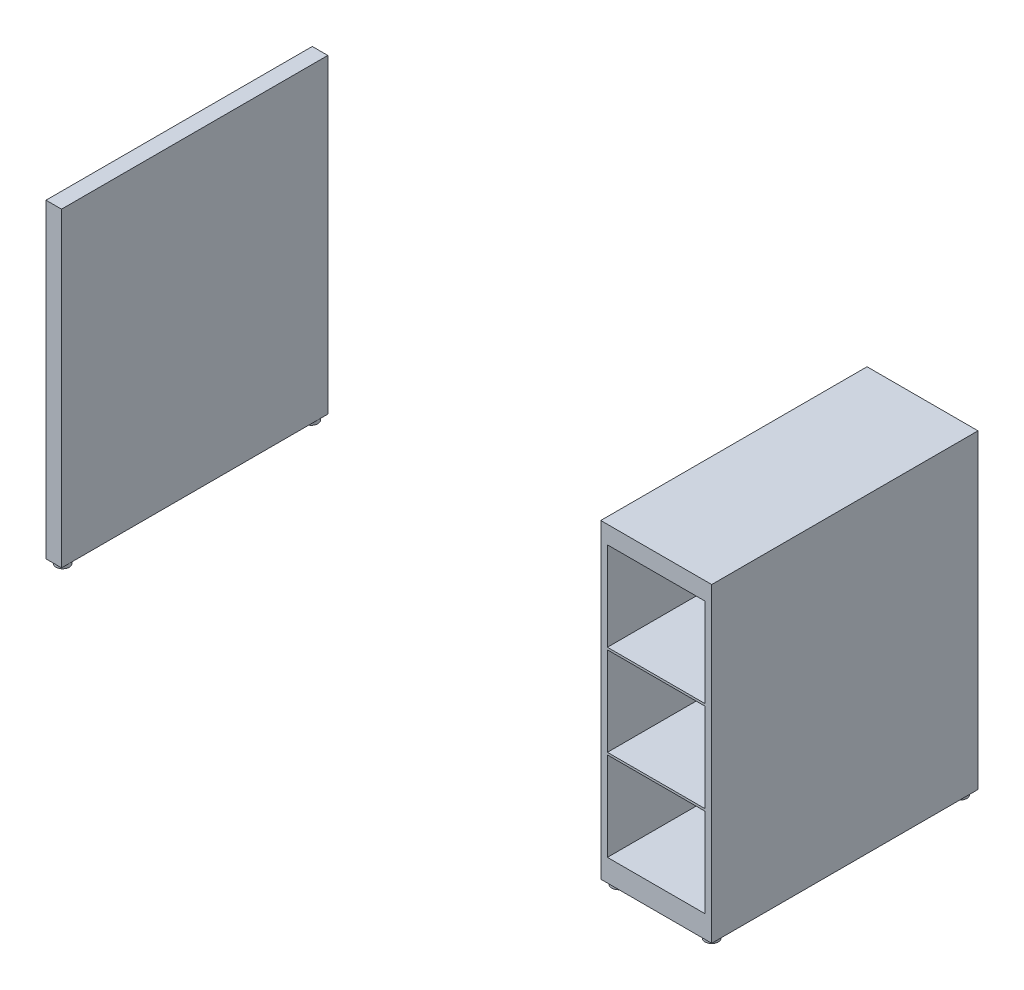
from build123d import *

# Parameters (mm, degrees)
SKETCH1_W           = 1500
SKETCH1_H           = 600
BOSS_EXTRUDE1_DEPTH = 700
SKETCH4_W           = 1215
SKETCH4_H           = 700
CUT_EXTRUDE2_DEPTH  = 750
SKETCH5_W           = 220.000567729
SKETCH5_H           = 200
CUT_EXTRUDE3_DEPTH  = 580
SKETCH6_R           = 15
BOSS_EXTRUDE3_DEPTH = 10


with BuildPart() as part:
    # Sketch1 → Boss-Extrude1 (new body)
    with BuildSketch(Plane(origin=(0, 0, 0), x_dir=(1, 0, 0), z_dir=(0, 1, 0))):
        Rectangle(SKETCH1_W, SKETCH1_H)
    extrude(amount=BOSS_EXTRUDE1_DEPTH)

    # Sketch4 → Cut-Extrude2 (cut)
    with BuildSketch(Plane.XY.offset(300)):
        with Locations((-107.5, 350)):
            Rectangle(SKETCH4_W, SKETCH4_H)
    extrude(amount=-CUT_EXTRUDE2_DEPTH, mode=Mode.SUBTRACT)

    # Sketch5 → Cut-Extrude3 (cut)
    with BuildSketch(Plane.XY.offset(300)):
        Polygon((515, 660), (515, 460.099912453), (735.000567729, 460.099912453), (735.000567729, 660.099912453), align=None)
        with Locations((625.000283865, 355.099912453)):
            Rectangle(SKETCH5_W, SKETCH5_H)
        with Locations((625.000283865, 150.099912453)):
            Rectangle(SKETCH5_W, SKETCH5_H)
    extrude(amount=-CUT_EXTRUDE3_DEPTH, mode=Mode.SUBTRACT)

    # Sketch6 → Boss-Extrude3 (add)
    with BuildSketch(Plane(origin=(0, 0, 0), x_dir=(-1, 0, 0), z_dir=(0, -1, 0))):
        with Locations((732.5, -280)):
            Circle(SKETCH6_R)
        with Locations((732.5, 280)):
            Circle(SKETCH6_R)
        with Locations((-520, -280)):
            Circle(SKETCH6_R)
        with Locations((-520, 280)):
            Circle(SKETCH6_R)
        with Locations((-730, 280)):
            Circle(SKETCH6_R)
        with Locations((-730, -280)):
            Circle(SKETCH6_R)
    extrude(amount=BOSS_EXTRUDE3_DEPTH)


solid = part.part
